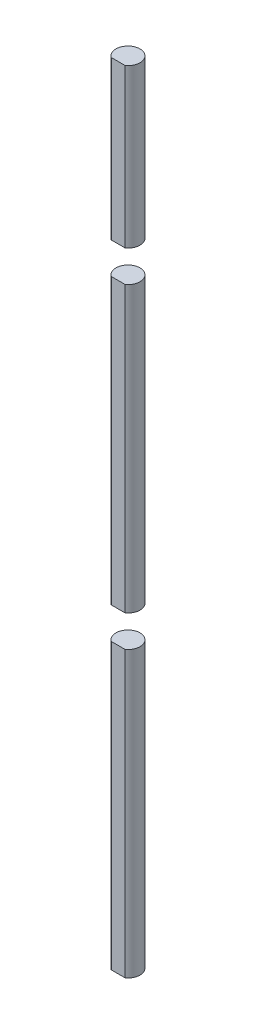
from build123d import *

# Parameters (mm, degrees)
BOSS_EXTRUDE1_DEPTH = 130
SKETCH2_W           = 10.164440157
SKETCH2_H           = 5
SKETCH2_W_2         = 5.261886041
SKETCH2_W_3         = 2.186621348
SKETCH2_W_4         = 8.459625722
SKETCH2_W_5         = 16.182032923
SKETCH2_W_6         = 7.149876699
SKETCH2_W_7         = 3.543697944
CUT_EXTRUDE1_DEPTH  = 130


with BuildPart() as part:
    # Sketch1 → Boss-Extrude1 (new body)
    with BuildSketch(Plane(origin=(0, 0, 0), x_dir=(1, 0, 0), z_dir=(0, 1, 0))):
        with BuildLine():
            Line((-1.093310674, -1.553921417), (1.093310674, -1.553921417))
            ThreePointArc((1.093310674, -1.553921417), (0, 1.9), (-1.093310674, -1.553921417))
        make_face()
    extrude(amount=BOSS_EXTRUDE1_DEPTH)

    # Sketch2 → Cut-Extrude1 (cut)
    with BuildSketch(Plane.XY.offset(1.553921417)):
        with Locations((6.175530753, 127.5)):
            Rectangle(SKETCH2_W, SKETCH2_H)
        with Locations((-3.724253695, 127.5)):
            Rectangle(SKETCH2_W_2, SKETCH2_H)
        with Locations((0, 127.5)):
            Rectangle(SKETCH2_W_3, SKETCH2_H)
        with Locations((0, 97.5)):
            Rectangle(SKETCH2_W_3, SKETCH2_H)
        with Locations((-5.323123535, 97.5)):
            Rectangle(SKETCH2_W_4, SKETCH2_H)
        with Locations((9.184327136, 97.5)):
            Rectangle(SKETCH2_W_5, SKETCH2_H)
        with Locations((-4.668249024, 47.5)):
            Rectangle(SKETCH2_W_6, SKETCH2_H)
        with Locations((0, 47.5)):
            Rectangle(SKETCH2_W_3, SKETCH2_H)
        with Locations((2.865159646, 47.5)):
            Rectangle(SKETCH2_W_7, SKETCH2_H)
    extrude(amount=-CUT_EXTRUDE1_DEPTH, mode=Mode.SUBTRACT)


solid = part.part
